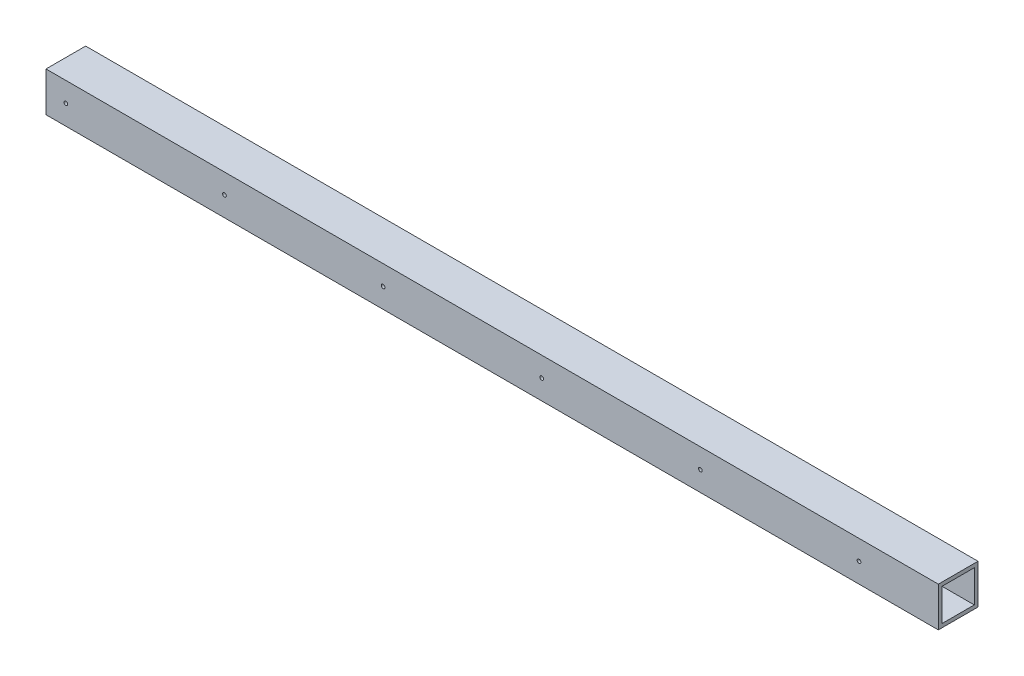
from build123d import *

# Parameters (mm, degrees)
SKETCH1_W           = 50.8
SKETCH1_H           = 50.8
SKETCH1_W_2         = 41.275
SKETCH1_H_2         = 41.275
BOSS_EXTRUDE1_DEPTH = 1143
SKETCH2_R           = 2.38125
CUT_EXTRUDE1_DEPTH  = 51.8
LPATTERN1_COUNT     = 6
LPATTERN1_PITCH     = 203.2
SKETCH3_R           = 2.38125
CUT_EXTRUDE2_DEPTH  = 4.7625
LPATTERN2_COUNT     = 6
LPATTERN2_PITCH     = 203.2


with BuildPart() as part:
    # Sketch1 → Boss-Extrude1 (new body)
    with BuildSketch(Plane(origin=(0, 0, 0), x_dir=(0, 0, -1), z_dir=(1, 0, 0))):
        with Locations((25.4, 25.4)):
            Rectangle(SKETCH1_W, SKETCH1_H)
        with Locations((25.4, 25.4)):
            Rectangle(SKETCH1_W_2, SKETCH1_H_2, mode=Mode.SUBTRACT)
    extrude(amount=BOSS_EXTRUDE1_DEPTH)

    # Sketch2 → Cut-Extrude1 (cut, through all)
    with BuildSketch(Plane(origin=(0, 0, -50.8), x_dir=(-1, 0, 0), z_dir=(0, 0, -1))):
        with Locations((-1041.4, 25.4)):
            Circle(SKETCH2_R)
    cut_extrude1 = extrude(amount=-CUT_EXTRUDE1_DEPTH, mode=Mode.SUBTRACT)

    # LPattern1: Cut-Extrude1 ×6
    with Locations(*[(-i * LPATTERN1_PITCH, 0, 0) for i in range(1, LPATTERN1_COUNT)]):
        add(cut_extrude1, mode=Mode.SUBTRACT)

    # Sketch3 → Cut-Extrude2 (cut)
    with BuildSketch(Plane.XZ):
        with Locations((101.6, -25.4)):
            Circle(SKETCH3_R)
    cut_extrude2 = extrude(amount=-CUT_EXTRUDE2_DEPTH, mode=Mode.SUBTRACT)

    # LPattern2: Cut-Extrude2 ×6
    with Locations(*[(i * LPATTERN2_PITCH, 0, 0) for i in range(1, LPATTERN2_COUNT)]):
        add(cut_extrude2, mode=Mode.SUBTRACT)


solid = part.part
